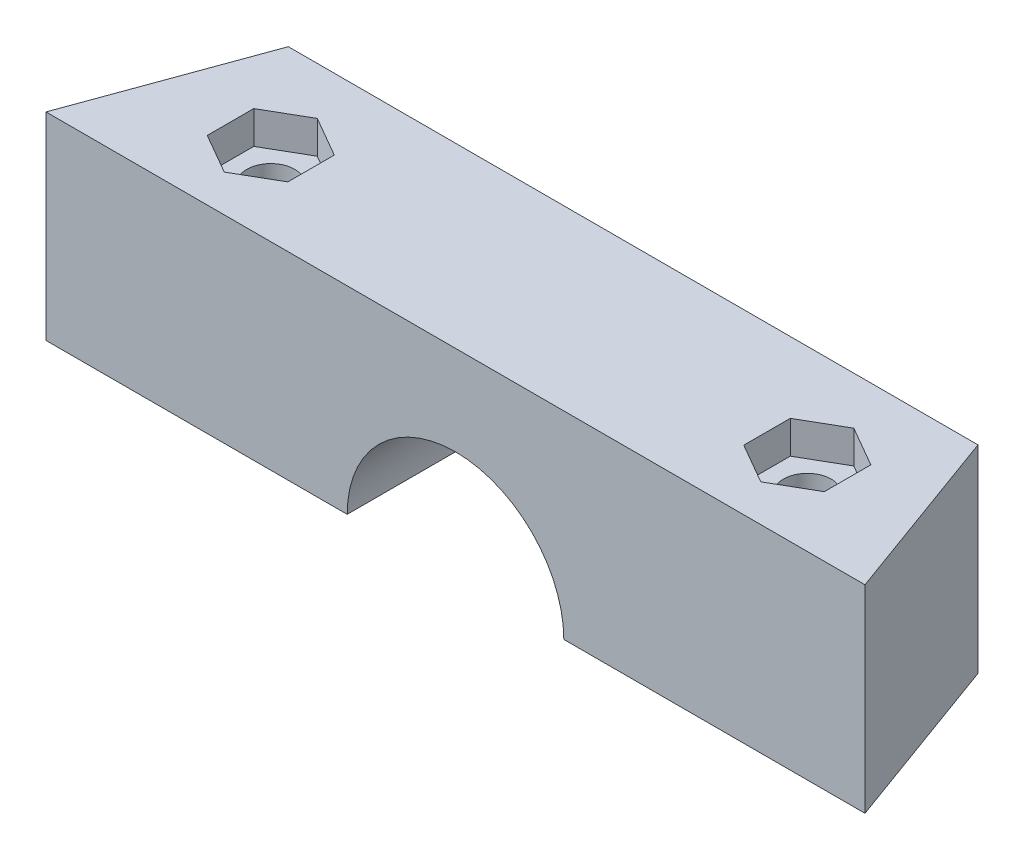
from build123d import *

# Parameters (mm, degrees)
BOSS_EXTRUDE3_DEPTH   = 14.5
SKETCH8_R             = 7.935
CUT_EXTRUDE3_DEPTH    = 88
CUT_EXTRUDE7_DEPTH    = 2.4
CUT_EXTRUDE8_DEPTH    = 2.4
F_1_0MM_DOWEL_HOLE1_D = 3.5
CUT_EXTRUDE10_DEPTH   = 22.4


with BuildPart() as part:
    # Sketch6 → Boss-Extrude3 (new body)
    with BuildSketch(Plane(origin=(0, 0, 0), x_dir=(1, 0, 0), z_dir=(0, 1, 0))):
        Polygon((-21.836914056, -7.954033585), (8.163085944, -7.954033585), (23.163085944, -49.166194877), (-36.836914056, -49.166194877), align=None)
    extrude(amount=BOSS_EXTRUDE3_DEPTH)

    # Sketch8 → Cut-Extrude3 (cut)
    with BuildSketch(Plane.XY.offset(49.166194877)):
        with Locations((-6.836914056, 0)):
            Circle(SKETCH8_R)
    extrude(amount=-CUT_EXTRUDE3_DEPTH, mode=Mode.SUBTRACT)

    # Sketch16 → Cut-Extrude7 (cut)
    with BuildSketch(Plane(origin=(0, 14.5, 0), x_dir=(1, 0, 0), z_dir=(0, 1, 0))):
        Polygon((-26.489739818, -46.452561466), (-23.539739818, -44.749378171), (-23.539739818, -41.343011583), (-26.489739818, -39.639828289), (-29.439739818, -41.343011583), (-29.439739818, -44.749378171), align=None)
        Polygon((12.815911706, -46.452561466), (15.765911706, -44.749378171), (15.765911706, -41.343011583), (12.815911706, -39.639828289), (9.865911706, -41.343011583), (9.865911706, -44.749378171), align=None)
    extrude(amount=-CUT_EXTRUDE7_DEPTH, mode=Mode.SUBTRACT)

    # Sketch17 → Cut-Extrude8 (cut)
    with BuildSketch(Plane.XZ):
        Polygon((-26.489739818, 39.639828289), (-23.539739818, 41.343011583), (-23.539739818, 44.749378171), (-26.489739818, 46.452561466), (-29.439739818, 44.749378171), (-29.439739818, 41.343011583), align=None)
        Polygon((12.815911706, 39.639828289), (15.765911706, 41.343011583), (15.765911706, 44.749378171), (12.815911706, 46.452561466), (9.865911706, 44.749378171), (9.865911706, 41.343011583), align=None)
    extrude(amount=-CUT_EXTRUDE8_DEPTH, mode=Mode.SUBTRACT)

    # Ø1.0mm Dowel Hole1 (through all)
    with Locations(Plane(origin=(-26.489739818, 14.5, 43.046194877), x_dir=(0, 0, 1), z_dir=(0, 1, 0))):
        with Locations((0, 0), (0, 39.305651524)):
            Hole(F_1_0MM_DOWEL_HOLE1_D / 2)

    # Sketch20 → Cut-Extrude10 (cut)
    with BuildSketch(Plane(origin=(0, 14.5, 0), x_dir=(1, 0, 0), z_dir=(0, 1, 0))):
        Polygon((-32.09934406, -36.149828289), (18.425515948, -36.149828289), (8.163085944, -7.954033585), (-21.836914056, -7.954033585), align=None)
    extrude(amount=-CUT_EXTRUDE10_DEPTH, mode=Mode.SUBTRACT)


solid = part.part
